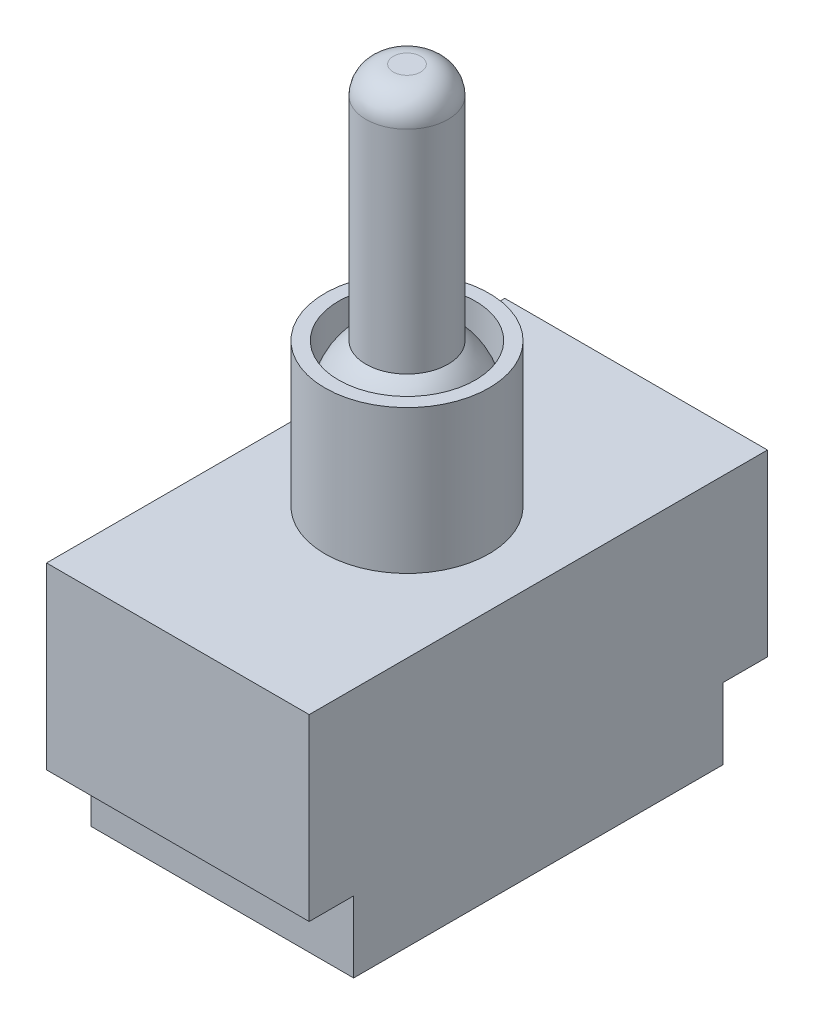
from build123d import *

# Parameters (mm, degrees)
SKETCH1_W           = 19.2
SKETCH1_H           = 33.5
BOSS_EXTRUDE1_DEPTH = 13.1
SKETCH2_R           = 6
BOSS_EXTRUDE2_DEPTH = 10.5
SKETCH4_R           = 5
CUT_EXTRUDE1_DEPTH  = 4
SKETCH5_R           = 3
BOSS_EXTRUDE3_DEPTH = 21.5
REVOLVE2_ANGLE      = 180
FILLET1_R           = 2
SKETCH6_W           = 19.2
SKETCH6_H           = 27
BOSS_EXTRUDE4_DEPTH = 5.2


with BuildPart() as part:
    # Sketch1 → Boss-Extrude1 (new body)
    with BuildSketch(Plane(origin=(0, 0, 0), x_dir=(1, 0, 0), z_dir=(0, 1, 0))):
        Rectangle(SKETCH1_W, SKETCH1_H)
    extrude(amount=BOSS_EXTRUDE1_DEPTH)

    # Sketch2 → Boss-Extrude2 (add)
    with BuildSketch(Plane(origin=(0, 13.1, 0), x_dir=(1, 0, 0), z_dir=(0, 1, 0))):
        with Locations(Location((0, 0, 0), (0, 0, 270))):  # turned: the seam where the file's is
            Circle(SKETCH2_R)
    extrude(amount=BOSS_EXTRUDE2_DEPTH)

    # Sketch4 → Cut-Extrude1 (cut)
    with BuildSketch(Plane(origin=(0, 23.6, 0), x_dir=(1, 0, 0), z_dir=(0, 1, 0))):
        with Locations(Location((0, 0, 0), (0, 0, 270))):  # turned: the seam where the file's is
            Circle(SKETCH4_R)
    extrude(amount=-CUT_EXTRUDE1_DEPTH, mode=Mode.SUBTRACT)

    # Sketch5 → Boss-Extrude3 (add)
    with BuildSketch(Plane(origin=(0, 19.6, 0), x_dir=(1, 0, 0), z_dir=(0, 1, 0))):
        with Locations(Location((0, 0, 0), (0, 0, 270))):  # turned: the seam where the file's is
            Circle(SKETCH5_R)
    extrude(amount=BOSS_EXTRUDE3_DEPTH)

    # Sketch3 → Revolve2 (revolve)
    with BuildSketch(Plane(origin=(0, 19.6, 0), x_dir=(1, 0, 0), z_dir=(0, 1, 0))):
        with BuildLine():
            Line((0, -5), (0, 5))
            ThreePointArc((0, 5), (-5, 0), (0, -5))
        make_face()
    revolve(axis=Axis((0, 19.6, 6), (0, 0, -1)), revolution_arc=REVOLVE2_ANGLE)

    # Fillet1
    fillet1_edges = [part.edges().sort_by_distance(p)[0] for p in [
        (0, 41.1, -3),
    ]]
    fillet(fillet1_edges, radius=FILLET1_R)

    # Sketch6 → Boss-Extrude4 (add)
    with BuildSketch(Plane.XZ):
        Rectangle(SKETCH6_W, SKETCH6_H)
    extrude(amount=BOSS_EXTRUDE4_DEPTH)


solid = part.part
